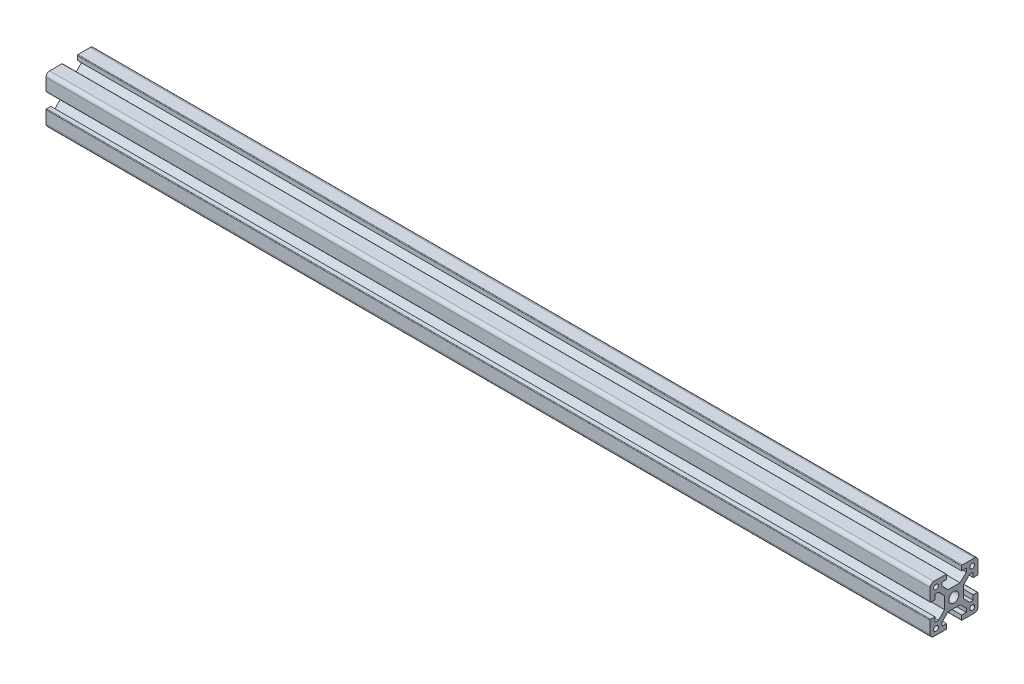
from build123d import *

# Parameters (mm, degrees)
SKETCH11_R          = 1
SKETCH11_R_2        = 2.1
XA_XA_2020T_1_DEPTH = 400
SKETCH14_W          = 25.965356462
SKETCH14_H          = 24.672555304
CUT_EXTRUDE2_DEPTH  = 30


with BuildPart() as part:
    # Sketch11 → Xa XA-2020T(1) (new body)
    with BuildSketch(Plane(origin=(0, 0, 0), x_dir=(0, 0, -1), z_dir=(1, 0, 0))):
        with BuildLine():
            Line((-9.889124212, 8.439448346), (-9.889124212, 3.289448346))
            ThreePointArc((-9.889124212, 3.289448346), (-9.815900907, 3.112671651), (-9.639124212, 3.039448346))
            Line((-9.639124212, 3.039448346), (-7.889124212, 3.039448346))
            Line((-7.889124212, 3.039448346), (-7.889124212, 5.039448346))
            Line((-7.889124212, 5.039448346), (-6.41690199, 5.039448346))
            Line((-6.41690199, 5.039448346), (-3.889124212, 2.439448346))
            Line((-3.889124212, 2.439448346), (-3.889124212, -2.560551654))
            Line((-3.889124212, -2.560551654), (-6.41690199, -5.160551654))
            Line((-6.41690199, -5.160551654), (-7.889124212, -5.160551654))
            Line((-7.889124212, -5.160551654), (-7.889124212, -3.160551654))
            Line((-7.889124212, -3.160551654), (-9.639124212, -3.160551654))
            ThreePointArc((-9.639124212, -3.160551654), (-9.815900907, -3.233774958), (-9.889124212, -3.410551654))
            Line((-9.889124212, -3.410551654), (-9.889124212, -8.560551654))
            ThreePointArc((-9.889124212, -8.560551654), (-9.449784384, -9.621211825), (-8.389124212, -10.060551654))
            Line((-8.389124212, -10.060551654), (-3.239124212, -10.060551654))
            ThreePointArc((-3.239124212, -10.060551654), (-3.062347516, -9.987328349), (-2.989124212, -9.810551654))
            Line((-2.989124212, -9.810551654), (-2.989124212, -8.060551654))
            Line((-2.989124212, -8.060551654), (-4.989124212, -8.060551654))
            Line((-4.989124212, -8.060551654), (-4.989124212, -6.588329431))
            Line((-4.989124212, -6.588329431), (-2.389124212, -4.060551654))
            Line((-2.389124212, -4.060551654), (2.610875788, -4.060551654))
            Line((2.610875788, -4.060551654), (5.210875788, -6.588329431))
            Line((5.210875788, -6.588329431), (5.210875788, -8.060551654))
            Line((5.210875788, -8.060551654), (3.210875788, -8.060551654))
            Line((3.210875788, -8.060551654), (3.210875788, -9.810551654))
            ThreePointArc((3.210875788, -9.810551654), (3.284099093, -9.987328349), (3.460875788, -10.060551654))
            Line((3.460875788, -10.060551654), (8.610875788, -10.060551654))
            ThreePointArc((8.610875788, -10.060551654), (9.67153596, -9.621211825), (10.110875788, -8.560551654))
            Line((10.110875788, -8.560551654), (10.110875788, -3.410551654))
            ThreePointArc((10.110875788, -3.410551654), (10.037652484, -3.233774958), (9.860875788, -3.160551654))
            Line((9.860875788, -3.160551654), (8.110875788, -3.160551654))
            Line((8.110875788, -3.160551654), (8.110875788, -5.160551654))
            Line((8.110875788, -5.160551654), (6.638653566, -5.160551654))
            Line((6.638653566, -5.160551654), (4.110875788, -2.560551654))
            Line((4.110875788, -2.560551654), (4.110875788, 2.439448346))
            Line((4.110875788, 2.439448346), (6.638653566, 5.039448346))
            Line((6.638653566, 5.039448346), (8.110875788, 5.039448346))
            Line((8.110875788, 5.039448346), (8.110875788, 3.039448346))
            Line((8.110875788, 3.039448346), (9.860875788, 3.039448346))
            ThreePointArc((9.860875788, 3.039448346), (10.037652484, 3.112671651), (10.110875788, 3.289448346))
            Line((10.110875788, 3.289448346), (10.110875788, 8.439448346))
            ThreePointArc((10.110875788, 8.439448346), (9.67153596, 9.500108518), (8.610875788, 9.939448346))
            Line((8.610875788, 9.939448346), (3.460875788, 9.939448346))
            ThreePointArc((3.460875788, 9.939448346), (3.284099093, 9.866225042), (3.210875788, 9.689448346))
            Line((3.210875788, 9.689448346), (3.210875788, 7.939448346))
            Line((3.210875788, 7.939448346), (5.210875788, 7.939448346))
            Line((5.210875788, 7.939448346), (5.210875788, 6.467226124))
            Line((5.210875788, 6.467226124), (2.610875788, 3.939448346))
            Line((2.610875788, 3.939448346), (-2.389124212, 3.939448346))
            Line((-2.389124212, 3.939448346), (-4.989124212, 6.467226124))
            Line((-4.989124212, 6.467226124), (-4.989124212, 7.939448346))
            Line((-4.989124212, 7.939448346), (-2.989124212, 7.939448346))
            Line((-2.989124212, 7.939448346), (-2.989124212, 9.689448346))
            ThreePointArc((-2.989124212, 9.689448346), (-3.062347516, 9.866225042), (-3.239124212, 9.939448346))
            Line((-3.239124212, 9.939448346), (-8.389124212, 9.939448346))
            ThreePointArc((-8.389124212, 9.939448346), (-9.449784384, 9.500108518), (-9.889124212, 8.439448346))
        make_face()
        with Locations((-7.439124212, 7.489448346)):
            Circle(SKETCH11_R, mode=Mode.SUBTRACT)
        with Locations((7.660875788, 7.489448346)):
            Circle(SKETCH11_R, mode=Mode.SUBTRACT)
        with Locations((-7.439124212, -7.610551654)):
            Circle(SKETCH11_R, mode=Mode.SUBTRACT)
        with Locations((7.660875788, -7.610551654)):
            Circle(SKETCH11_R, mode=Mode.SUBTRACT)
        Circle(SKETCH11_R_2, mode=Mode.SUBTRACT)
    extrude(amount=XA_XA_2020T_1_DEPTH)

    # Sketch14 → Cut-Extrude2 (cut)
    with BuildSketch(Plane(origin=(400, 0, 0), x_dir=(0, 0, -1), z_dir=(1, 0, 0))):
        Rectangle(SKETCH14_W, SKETCH14_H)
    extrude(amount=-CUT_EXTRUDE2_DEPTH, mode=Mode.SUBTRACT)


solid = part.part
